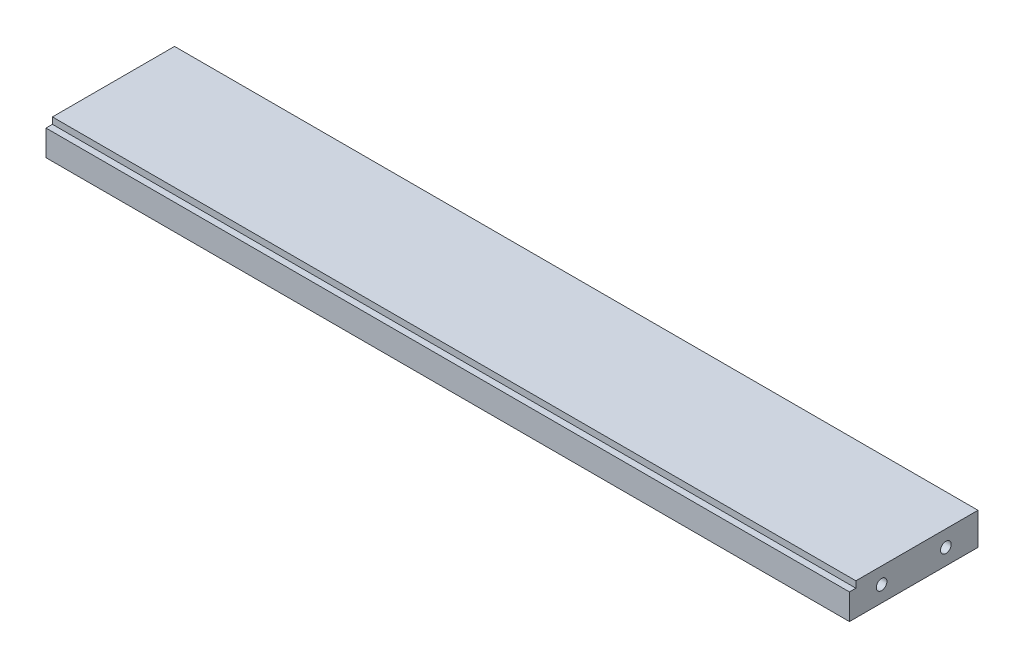
from build123d import *

# Parameters (mm, degrees)
SKETCH1_W                  = 250
SKETCH1_H                  = 40
BOSS_EXTRUDE1_DEPTH        = 5
SKETCH5_W                  = 2
SKETCH5_H                  = 2
CUT_EXTRUDE2_DEPTH         = 126
CUT_EXTRUDE2_DEPTH_BACK    = 126
M4_TAPPED_HOLE1_AT_2_COUNT = 2
M4_TAPPED_HOLE1_AT_2_PITCH = 20
M4X0_7_TAPPED_HOLE1_D      = 3.3
M4X0_7_TAPPED_HOLE1_DEPTH  = 14
M4X0_7_TAPPED_HOLE1_TIP    = 0.991420021


with BuildPart() as part:
    # Sketch1 → Boss-Extrude1 (new body, symmetric)
    with BuildSketch(Plane(origin=(0, 0, 0), x_dir=(1, 0, 0), z_dir=(0, 1, 0))):
        Rectangle(SKETCH1_W, SKETCH1_H)
    extrude(amount=BOSS_EXTRUDE1_DEPTH, both=True)

    # Sketch5 → Cut-Extrude2 (cut, two sides)
    with BuildSketch(Plane(origin=(0, 0, 0), x_dir=(0, 0, -1), z_dir=(1, 0, 0))) as cut_extrude2_sk:
        with Locations((-19, 4)):
            Rectangle(SKETCH5_W, SKETCH5_H)
    extrude(amount=CUT_EXTRUDE2_DEPTH, mode=Mode.SUBTRACT)
    extrude(cut_extrude2_sk.sketch, amount=-CUT_EXTRUDE2_DEPTH_BACK, mode=Mode.SUBTRACT)

    # Sketch8 → M4 Tapped Hole1 (revolve, cut)
    with BuildSketch(Plane(origin=(125, 0, -10), x_dir=(0, 0, -1), z_dir=(0, 1, 0))):
        Polygon((0, 0), (0, 14.991420021), (1.65, 14), (1.65, 0), align=None)
    m4_tapped_hole1 = revolve(axis=Axis((131.35, 0, -10), (-1, 0, 0)), mode=Mode.SUBTRACT)

    # M4 Tapped Hole1 at 2: M4 Tapped Hole1 ×2
    with Locations(*[(0, 0, i * M4_TAPPED_HOLE1_AT_2_PITCH) for i in range(1, M4_TAPPED_HOLE1_AT_2_COUNT)]):
        add(m4_tapped_hole1, mode=Mode.SUBTRACT)

    # Mirror1: M4 Tapped Hole1 across plane
    add(m4_tapped_hole1.mirror(Plane(origin=(0, 0, 0), x_dir=(0, 0, 1), z_dir=(1, 0, 0))), mode=Mode.SUBTRACT)

    # Mirror1 copy 1 sketch → Mirror1 copy 1 (revolve, cut)
    with BuildSketch(Plane(origin=(-125, 0, 10), x_dir=(0, 0, -1), z_dir=(0, 1, 0))):
        Polygon((0, 0), (0, -14.991420021), (1.65, -14), (1.65, 0), align=None)
    revolve(axis=Axis((-131.35, 0, 10), (-1, 0, 0)), mode=Mode.SUBTRACT)

    # M4x0.7 Tapped Hole1
    with Locations(Plane(origin=(0, 0, -20), x_dir=(-1, 0, 0), z_dir=(0, 0, -1))):
        with Locations((-75, 0), (75, 0)):
            Hole(M4X0_7_TAPPED_HOLE1_D / 2, depth=M4X0_7_TAPPED_HOLE1_DEPTH)
            with Locations((0, 0, -(M4X0_7_TAPPED_HOLE1_DEPTH + M4X0_7_TAPPED_HOLE1_TIP / 2))):  # 118° drill point
                Cone(0, M4X0_7_TAPPED_HOLE1_D / 2, M4X0_7_TAPPED_HOLE1_TIP, mode=Mode.SUBTRACT)


solid = part.part
